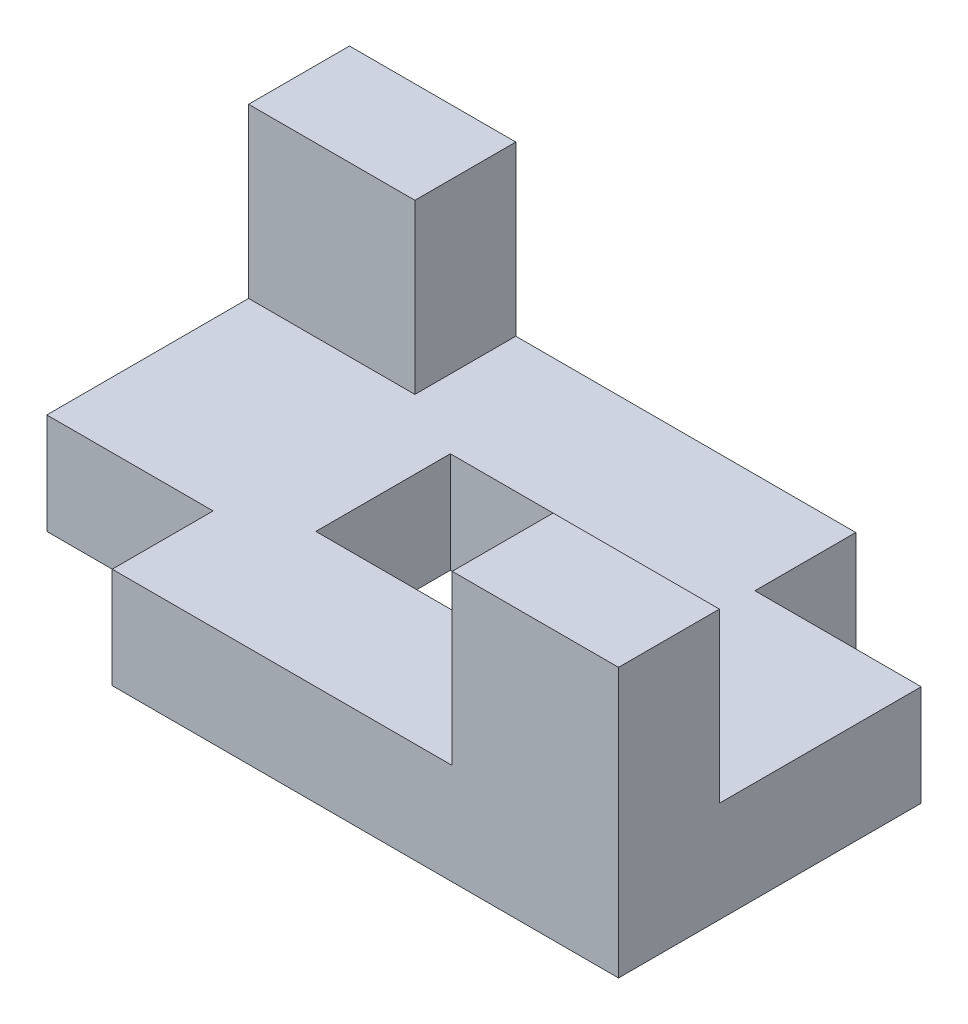
from build123d import *

# Parameters (mm, degrees)
SKETCH1_W           = 100
SKETCH1_H           = 60
BOSS_EXTRUDE1_DEPTH = 15
SKETCH1_4_W         = 24.726477024
SKETCH1_4_H         = 15
BOSS_EXTRUDE2_DEPTH = 40
SKETCH1_5_W         = 24.726477024
SKETCH1_5_H         = 15
CUT_EXTRUDE1_DEPTH  = 40
SKETCH1_6_W         = 30
SKETCH1_6_H         = 20
CUT_EXTRUDE2_DEPTH  = 40


with BuildPart() as part:
    # Sketch1 → Boss-Extrude1 (new body)
    with BuildSketch(Plane(origin=(0, 0, 0), x_dir=(1, 0, 0), z_dir=(0, 1, 0))):
        Rectangle(SKETCH1_W, SKETCH1_H)
    extrude(amount=BOSS_EXTRUDE1_DEPTH)

    # Sketch1_4 → Boss-Extrude2 (add)
    with BuildSketch(Plane(origin=(0, 0, 0), x_dir=(1, 0, 0), z_dir=(0, 1, 0))):
        with Locations((-37.636761488, 22.5)):
            Rectangle(SKETCH1_4_W, SKETCH1_4_H)
        with Locations((37.636761488, -22.5)):
            Rectangle(SKETCH1_4_W, SKETCH1_4_H)
    extrude(amount=BOSS_EXTRUDE2_DEPTH)

    # Sketch1_5 → Cut-Extrude1 (cut)
    with BuildSketch(Plane(origin=(0, 0, 0), x_dir=(1, 0, 0), z_dir=(0, 1, 0))):
        with Locations((37.636761488, 22.5)):
            Rectangle(SKETCH1_5_W, SKETCH1_5_H)
        with Locations((-37.636761488, -22.5)):
            Rectangle(SKETCH1_5_W, SKETCH1_5_H)
    extrude(amount=CUT_EXTRUDE1_DEPTH, mode=Mode.SUBTRACT)

    # Sketch1_6 → Cut-Extrude2 (cut)
    with BuildSketch(Plane(origin=(0, 0, 0), x_dir=(1, 0, 0), z_dir=(0, 1, 0))):
        Rectangle(SKETCH1_6_W, SKETCH1_6_H)
    extrude(amount=CUT_EXTRUDE2_DEPTH, mode=Mode.SUBTRACT)


solid = part.part
